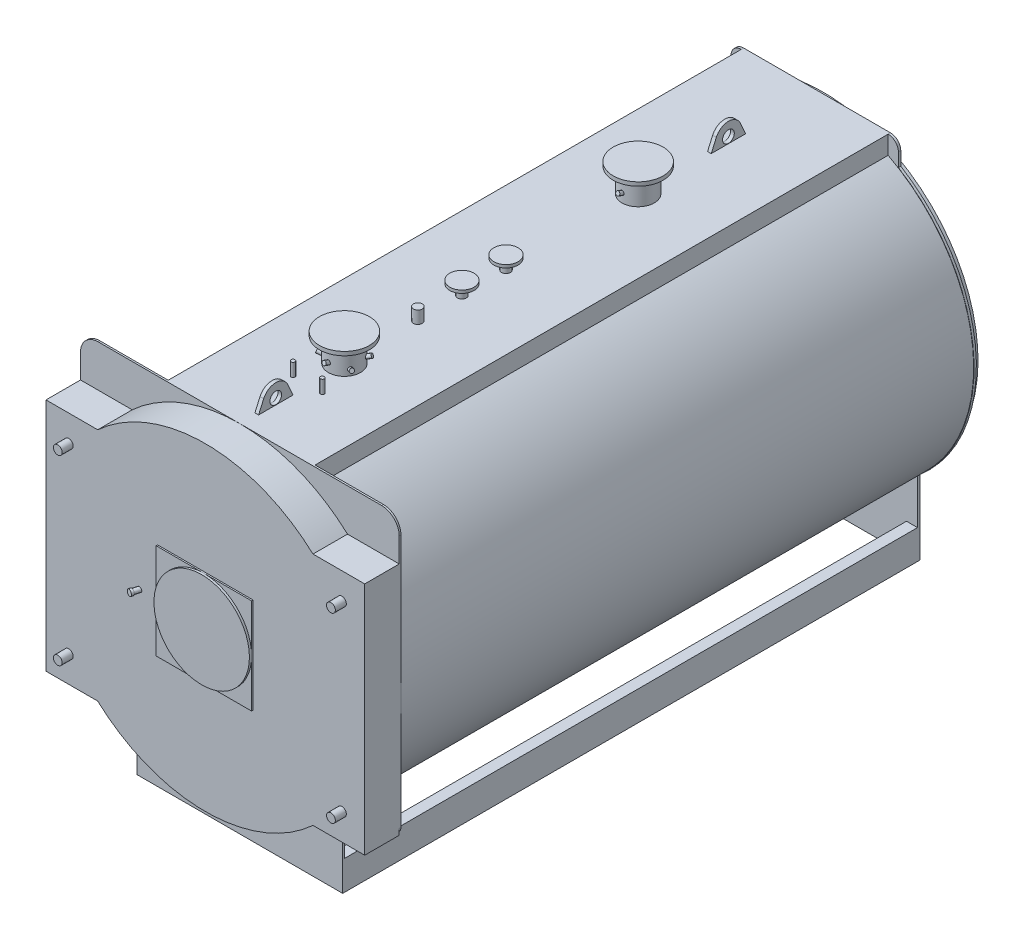
from build123d import *

# Parameters (mm, degrees)
PIASTRA_ANTERIORE_DEPTH       = 12
CORPO_DEPTH                   = 3902
PIASTRA_POSTERIORE_DEPTH      = 16
BASAMENTO_DEPTH               = 3902
ESTRUSIONE_ESTRUSIONE3_DEPTH  = 235
SCHIZZO8_W                    = 650
SCHIZZO8_H                    = 650
ESTRUSIONE_ESTRUSIONE4_DEPTH  = 10
SCHIZZO9_R                    = 325
ESTRUSIONE_ESTRUSIONE5_DEPTH  = 15
SCHIZZO12_R                   = 30
ESTRUSIONE_ESTRUSIONE6_DEPTH  = 75
SCHIZZO13_R                   = 109.55
ESTRUSIONE_ESTRUSIONE7_DEPTH  = 1275
SCHIZZO14_R                   = 170
ESTRUSIONE_ESTRUSIONE8_DEPTH  = 26
SCHIZZO13_3_R                 = 30.15
ESTRUSIONE_ESTRUSIONE9_DEPTH  = 1175
SCHIZZO15_R                   = 82.5
ESTRUSIONE_ESTRUSIONE10_DEPTH = 20
SCHIZZO13_4_R                 = 30.15
ESTRUSIONE_ESTRUSIONE11_DEPTH = 1170
SCHIZZO13_5_R                 = 13.35
ESTRUSIONE_ESTRUSIONE12_DEPTH = 1175
RIPETIZIONECIRCOLARE1_COUNT   = 3
SCHIZZO21_R                   = 24.15
ESTRUSIONE_ESTRUSIONE13_DEPTH = 149
SCHIZZO21_3_R                 = 24.15
ESTRUSIONE_ESTRUSIONE14_DEPTH = 50
SCHIZZO22_R                   = 75
ESTRUSIONE_ESTRUSIONE15_DEPTH = 16
SCHIZZO23_R                   = 40
GOLFARE_DEPTH                 = 12.5


with BuildPart() as part:
    # Schizzo1 → piastra anteriore (new body)
    with BuildSketch(Plane.XY):
        with BuildLine():
            Line((-965, 2420), (965, 2420))
            ThreePointArc((965, 2420), (1049.852813742, 2384.852813742), (1085, 2300))
            Line((1085, 2300), (1085, 575))
            ThreePointArc((1085, 575), (1073.284271247, 546.715728753), (1045, 535))
            Line((1045, 535), (700, 535))
            Line((700, 535), (700, 0))
            Line((700, 0), (-700, 0))
            Line((-700, 0), (-700, 535))
            Line((-700, 535), (-1045, 535))
            ThreePointArc((-1045, 535), (-1073.284271247, 546.715728753), (-1085, 575))
            Line((-1085, 575), (-1085, 2300))
            ThreePointArc((-1085, 2300), (-1049.852813742, 2384.852813742), (-965, 2420))
        make_face()
    extrude(amount=-PIASTRA_ANTERIORE_DEPTH)

    # Schizzo2 → corpo (add)
    with BuildSketch(Plane(origin=(0, 0, -12), x_dir=(-1, 0, 0), z_dir=(0, 0, -1))):
        with BuildLine():
            Line((500, 2295.107415866), (500, 2420))
            Line((500, 2420), (-500, 2420))
            Line((-500, 2420), (-500, 2295.107415866))
            ThreePointArc((-500, 2295.107415866), (0, 252.5), (500, 2295.107415866))
        make_face()
        with BuildLine():
            Line((490, 2289.021095155), (490, 2410))
            Line((490, 2410), (-490, 2410))
            Line((-490, 2410), (-490, 2289.021095155))
            ThreePointArc((-490, 2289.021095155), (0, 262.5), (490, 2289.021095155))
        make_face(mode=Mode.SUBTRACT)
    extrude(amount=CORPO_DEPTH)

    # Schizzo3 → piastra posteriore (add)
    with BuildSketch(Plane(origin=(0, 0, -3914), x_dir=(-1, 0, 0), z_dir=(0, 0, -1))):
        with BuildLine():
            Line((-570, 2258.214492954), (-570, 2350))
            ThreePointArc((-570, 2350), (-549.497474683, 2399.497474683), (-500, 2420))
            Line((-500, 2420), (500, 2420))
            ThreePointArc((500, 2420), (549.497474683, 2399.497474683), (570, 2350))
            Line((570, 2350), (570, 2258.214492954))
            ThreePointArc((570, 2258.214492954), (1082.02608689, 1415.277937754), (700, 506.009650237))
            Line((700, 506.009650237), (700, 0))
            Line((700, 0), (-700, 0))
            Line((-700, 0), (-700, 506.009650237))
            ThreePointArc((-700, 506.009650237), (-1082.02608689, 1415.277937754), (-570, 2258.214492954))
        make_face()
    extrude(amount=PIASTRA_POSTERIORE_DEPTH)

    # Schizzo5 → camera fumo (revolve)
    with BuildSketch(Plane(origin=(0, 0, 0), x_dir=(0, 0, -1), z_dir=(1, 0, 0)), mode=Mode.PRIVATE) as camera_fumo_sk:
        Polygon((3971, 1634), (4074, 1634), (4074, 1675), (4079, 1675), (4079, 1629), (3971, 1629), (3971, 1335), (3930, 1335), (3930, 2390), (3971, 2390), align=None)
    revolve(camera_fumo_sk.sketch.rotate(Axis((0, 1335, -3914), (0, 0, -1)), 90), axis=Axis((0, 1335, -3914), (0, 0, -1)))  # turned: the seam where the file's is

    # Schizzo6 → basamento (add)
    with BuildSketch(Plane(origin=(0, 0, -12), x_dir=(-1, 0, 0), z_dir=(0, 0, -1))):
        Polygon((-625, 0), (-700, 0), (-700, 200), (-625, 200), (-625, 190), (-690, 190), (-690, 10), (-625, 10), align=None)
    basamento = extrude(amount=BASAMENTO_DEPTH)

    # Specchia2: basamento across plane
    add(basamento.mirror(Plane(origin=(0, 0, 0), x_dir=(0, 0, 1), z_dir=(1, 0, 0))))

    # Schizzo7 → Estrusione-Estrusione3 (add)
    with BuildSketch(Plane.XY):
        with BuildLine():
            Line((732.956342493, 2135), (1085, 2135))
            Line((1085, 2135), (1085, 535))
            Line((1085, 535), (732.956342493, 535))
            ThreePointArc((732.956342493, 535), (0, 250), (-732.956342493, 535))
            Line((-732.956342493, 535), (-1085, 535))
            Line((-1085, 535), (-1085, 2135))
            Line((-1085, 2135), (-732.956342493, 2135))
            ThreePointArc((-732.956342493, 2135), (0, 2420), (732.956342493, 2135))
        make_face()
    extrude(amount=ESTRUSIONE_ESTRUSIONE3_DEPTH)

    # Schizzo8 → Estrusione-Estrusione4 (add)
    with BuildSketch(Plane.XY.offset(235)):
        with Locations((0, 1335)):
            Rectangle(SCHIZZO8_W, SCHIZZO8_H)
    extrude(amount=ESTRUSIONE_ESTRUSIONE4_DEPTH)

    # Schizzo9 → Estrusione-Estrusione5 (add)
    with BuildSketch(Plane.XY.offset(245)):
        with Locations((0, 1335)):
            Circle(SCHIZZO9_R)
    extrude(amount=ESTRUSIONE_ESTRUSIONE5_DEPTH)

    # Schizzo11 → Rivoluzione2 (revolve)
    with BuildSketch(Plane(origin=(0, 1335, 0), x_dir=(1, 0, 0), z_dir=(0, 1, 0)), mode=Mode.PRIVATE) as rivoluzione2_sk:
        Polygon((-464.268693957, -288.251490803), (-446.162357162, -220.677721947), (-430.031395863, -225), (-443.996627936, -277.118955636), (-440.809072709, -277.973058485), (-444.950177431, -293.427871705), align=None)
    revolve(rivoluzione2_sk.sketch.rotate(Axis((-450, 1335, 235), (-0.258819045, 0, 0.965925826)), 180), axis=Axis((-450, 1335, 235), (-0.258819045, 0, 0.965925826)))  # turned: the seam where the file's is

    # Schizzo12 → Estrusione-Estrusione6 (add)
    with BuildSketch(Plane.XY.offset(235)):
        with Locations((-930, 1955)):
            Circle(SCHIZZO12_R)
        with Locations(Location((930, 1955, 0), (0, 0, 180))):  # turned: the seam where the file's is
            Circle(SCHIZZO12_R)
        with Locations((930, 715)):
            Circle(SCHIZZO12_R)
        with Locations(Location((-930, 715, 0), (0, 0, 180))):  # turned: the seam where the file's is
            Circle(SCHIZZO12_R)
    extrude(amount=ESTRUSIONE_ESTRUSIONE6_DEPTH)

    # Schizzo13 → Estrusione-Estrusione7 (add)
    with BuildSketch(Plane(origin=(0, 1335, 0), x_dir=(1, 0, 0), z_dir=(0, 1, 0))):
        with Locations(Location((0, 712, 0), (0, 0, 90))):  # turned: the seam where the file's is
            Circle(SCHIZZO13_R)
        with Locations(Location((0, 2712, 0), (0, 0, 90))):  # turned: the seam where the file's is
            Circle(SCHIZZO13_R)
    extrude(amount=ESTRUSIONE_ESTRUSIONE7_DEPTH)

    # Schizzo14 → Estrusione-Estrusione8 (add)
    with BuildSketch(Plane(origin=(0, 2610, 0), x_dir=(1, 0, 0), z_dir=(0, 1, 0))):
        with Locations(Location((0, 712, 0), (0, 0, 270))):  # turned: the seam where the file's is
            Circle(SCHIZZO14_R)
        with Locations(Location((0, 2712, 0), (0, 0, 270))):  # turned: the seam where the file's is
            Circle(SCHIZZO14_R)
    extrude(amount=-ESTRUSIONE_ESTRUSIONE8_DEPTH)

    # Schizzo13_3 → Estrusione-Estrusione9 (add)
    with BuildSketch(Plane(origin=(0, 1335, 0), x_dir=(1, 0, 0), z_dir=(0, 1, 0))):
        with Locations(Location((0, 1812, 0), (0, 0, 90))):  # turned: the seam where the file's is
            Circle(SCHIZZO13_3_R)
        with Locations(Location((0, 1512, 0), (0, 0, 90))):  # turned: the seam where the file's is
            Circle(SCHIZZO13_3_R)
    extrude(amount=ESTRUSIONE_ESTRUSIONE9_DEPTH)

    # Schizzo15 → Estrusione-Estrusione10 (add)
    with BuildSketch(Plane(origin=(0, 2510, 0), x_dir=(1, 0, 0), z_dir=(0, 1, 0))):
        with Locations(Location((0, 1812, 0), (0, 0, 270))):  # turned: the seam where the file's is
            Circle(SCHIZZO15_R)
        with Locations(Location((0, 1512, 0), (0, 0, 270))):  # turned: the seam where the file's is
            Circle(SCHIZZO15_R)
    extrude(amount=-ESTRUSIONE_ESTRUSIONE10_DEPTH)

    # Schizzo13_4 → Estrusione-Estrusione11 (add)
    with BuildSketch(Plane(origin=(0, 1335, 0), x_dir=(1, 0, 0), z_dir=(0, 1, 0))):
        with Locations(Location((0, 1212, 0), (0, 0, 90))):  # turned: the seam where the file's is
            Circle(SCHIZZO13_4_R)
    extrude(amount=ESTRUSIONE_ESTRUSIONE11_DEPTH)

    # Schizzo13_5 → Estrusione-Estrusione12 (add)
    with BuildSketch(Plane(origin=(0, 1335, 0), x_dir=(1, 0, 0), z_dir=(0, 1, 0))):
        with Locations(Location((-100, 462, 0), (0, 0, 90))):  # turned: the seam where the file's is
            Circle(SCHIZZO13_5_R)
        with Locations(Location((100, 462, 0), (0, 0, 90))):  # turned: the seam where the file's is
            Circle(SCHIZZO13_5_R)
    extrude(amount=ESTRUSIONE_ESTRUSIONE12_DEPTH)

    # Schizzo16 → Rivoluzione3 (revolve)
    with BuildSketch(Plane(origin=(0, 0, 0), x_dir=(0, 0, -1), z_dir=(1, 0, 0))):
        Polygon((2573.149829072, 2490.664390077), (2577.75, 2503.303255826), (2624.734631039, 2486.20224866), (2620.134460112, 2473.56338291), align=None)
    revolve(axis=Axis((0, 2480, -2602.45), (0, 0.342020143, 0.939692621)))

    # Schizzo17 → Rivoluzione4 (revolve)
    with BuildSketch(Plane(origin=(0, 0, 0), x_dir=(0, 0, -1), z_dir=(1, 0, 0))):
        Polygon((573.149829072, 2490.664390077), (577.75, 2503.303255826), (624.734631039, 2486.20224866), (620.134460112, 2473.56338291), align=None)
    rivoluzione4 = revolve(axis=Axis((0, 2480, -602.45), (0, 0.342020143, 0.939692621)))

    # Schizzo18 → Rivoluzione5 (revolve)
    with BuildSketch(Plane(origin=(0, 0, 0), x_dir=(0, 0, -1), z_dir=(1, 0, 0)), mode=Mode.PRIVATE) as rivoluzione5_sk:
        Polygon((850.850170928, 2470.664390077), (846.25, 2483.303255826), (799.265368961, 2466.20224866), (803.865539888, 2453.56338291), align=None)
    rivoluzione5 = revolve(rivoluzione5_sk.sketch.rotate(Axis((0, 2460, -821.55), (0, 0.342020143, -0.939692621)), 180), axis=Axis((0, 2460, -821.55), (0, 0.342020143, -0.939692621)))  # turned: the seam where the file's is

    # RipetizioneCircolare1: Rivoluzione4, Rivoluzione5 ×3 about axis
    ripetizionecircolare1_axis = Axis((0, 0, -712), (0, 1, 0))
    add([rivoluzione4.rotate(ripetizionecircolare1_axis, i * 360 / RIPETIZIONECIRCOLARE1_COUNT) for i in range(1, RIPETIZIONECIRCOLARE1_COUNT)])
    add([rivoluzione5.rotate(ripetizionecircolare1_axis, i * 360 / RIPETIZIONECIRCOLARE1_COUNT) for i in range(1, RIPETIZIONECIRCOLARE1_COUNT)])

    # Schizzo21 → Estrusione-Estrusione13 (add)
    with BuildSketch(Plane(origin=(0, 0, -3930), x_dir=(-1, 0, 0), z_dir=(0, 0, -1))):
        with Locations((0, 125)):
            Circle(SCHIZZO21_R)
    extrude(amount=ESTRUSIONE_ESTRUSIONE13_DEPTH)

    # Schizzo21_3 → Estrusione-Estrusione14 (add)
    with BuildSketch(Plane(origin=(0, 0, -3930), x_dir=(-1, 0, 0), z_dir=(0, 0, -1))):
        with Locations(Location((0, 260, 0), (0, 0, 123.727665246))):  # turned: the seam where the file's is
            Circle(SCHIZZO21_3_R)
    extrude(amount=ESTRUSIONE_ESTRUSIONE14_DEPTH)

    # Schizzo22 → Estrusione-Estrusione15 (add)
    with BuildSketch(Plane(origin=(0, 0, -4079), x_dir=(-1, 0, 0), z_dir=(0, 0, -1))):
        with Locations((0, 125)):
            Circle(SCHIZZO22_R)
    extrude(amount=-ESTRUSIONE_ESTRUSIONE15_DEPTH)

    # Schizzo23 → golfare (add, symmetric)
    with BuildSketch(Plane(origin=(0, 0, 0), x_dir=(0, 0, -1), z_dir=(1, 0, 0))):
        with BuildLine():
            Line((107, 2322), (107, 2402))
            Line((107, 2402), (149.707899924, 2498.441875159))
            ThreePointArc((149.707899924, 2498.441875159), (232, 2552), (314.292100076, 2498.441875159))
            Line((314.292100076, 2498.441875159), (357, 2402))
            Line((357, 2402), (357, 2322))
            Line((357, 2322), (107, 2322))
        make_face()
        with Locations((232, 2462)):
            Circle(SCHIZZO23_R, mode=Mode.SUBTRACT)
        with BuildLine():
            Line((3189, 2322), (3189, 2402))
            Line((3189, 2402), (3231.707899924, 2498.441875159))
            ThreePointArc((3231.707899924, 2498.441875159), (3314, 2552), (3396.292100076, 2498.441875159))
            Line((3396.292100076, 2498.441875159), (3439, 2402))
            Line((3439, 2402), (3439, 2322))
            Line((3439, 2322), (3189, 2322))
        make_face()
        with Locations((3314, 2462)):
            Circle(SCHIZZO23_R, mode=Mode.SUBTRACT)
    extrude(amount=GOLFARE_DEPTH, both=True)


solid = part.part
